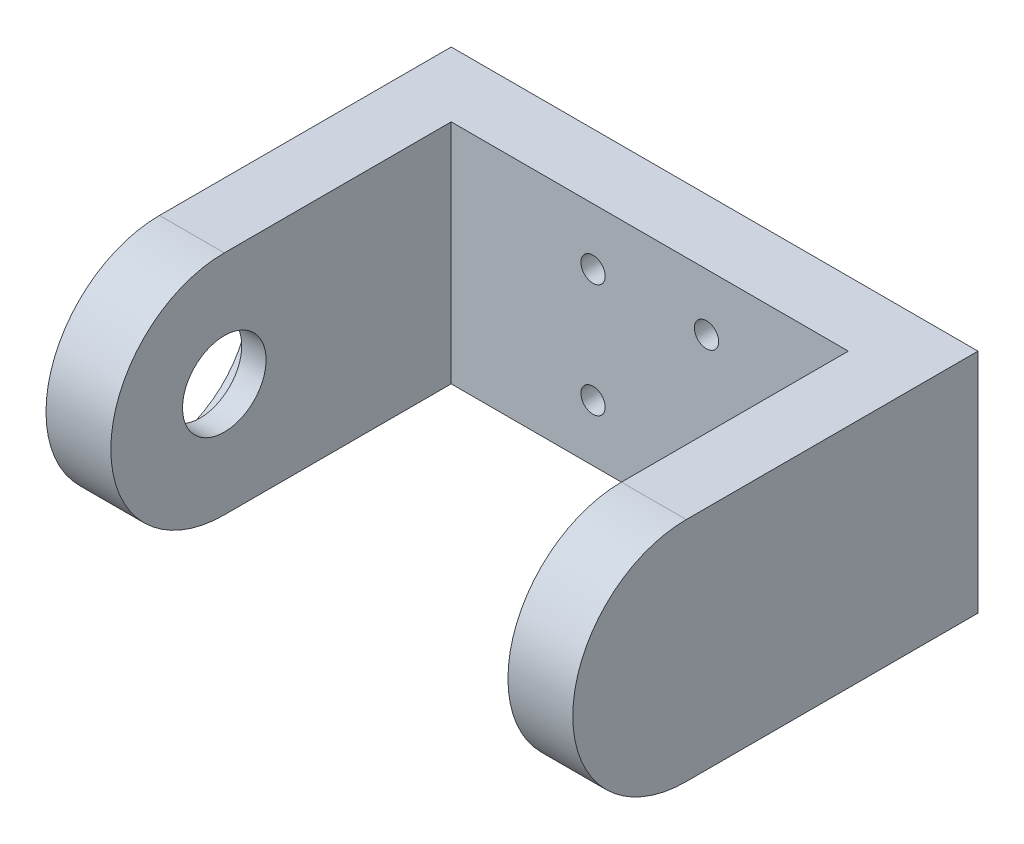
from build123d import *

# Parameters (mm, degrees)
CROQUIS1_W              = 65
CROQUIS1_H              = 28
SALIENTE_EXTRUIR1_DEPTH = 8
CROQUIS2_W              = 8
CROQUIS2_H              = 28
SALIENTE_EXTRUIR2_DEPTH = 28
CROQUIS3_R              = 14
SALIENTE_EXTRUIR3_DEPTH = 8
CROQUIS4_R              = 14
SALIENTE_EXTRUIR4_DEPTH = 8
CROQUIS5_R              = 11.115
CORTAR_EXTRUIR1_DEPTH   = 5
CROQUIS6_R              = 5.155
CORTAR_EXTRUIR2_DEPTH   = 8
CORTAR_EXTRUIR3_START   = -8
CROQUIS7_R              = 6.5
CORTAR_EXTRUIR3_DEPTH   = 5
CROQUIS8_R              = 1.5
CORTAR_EXTRUIR4_DEPTH   = 8


with BuildPart() as part:
    # Croquis1 → Saliente-Extruir1 (new body)
    with BuildSketch(Plane.XY):
        with Locations((32.5, 14)):
            Rectangle(CROQUIS1_W, CROQUIS1_H)
    extrude(amount=SALIENTE_EXTRUIR1_DEPTH)

    # Croquis2 → Saliente-Extruir2 (add)
    with BuildSketch(Plane.XY.offset(8)):
        with Locations((4, 14)):
            Rectangle(CROQUIS2_W, CROQUIS2_H)
        with Locations((61, 14)):
            Rectangle(CROQUIS2_W, CROQUIS2_H)
    extrude(amount=SALIENTE_EXTRUIR2_DEPTH)

    # Croquis3 → Saliente-Extruir3 (add)
    with BuildSketch(Plane.ZY):
        with Locations((36, 14)):
            Circle(CROQUIS3_R)
    extrude(amount=-SALIENTE_EXTRUIR3_DEPTH)

    # Croquis4 → Saliente-Extruir4 (add)
    with BuildSketch(Plane(origin=(65, 0, 0), x_dir=(0, 0, -1), z_dir=(1, 0, 0))):
        with Locations((-36, 14)):
            Circle(CROQUIS4_R)
    extrude(amount=-SALIENTE_EXTRUIR4_DEPTH)

    # Croquis5 → Cortar-Extruir1 (cut)
    with BuildSketch(Plane.ZY):
        with Locations((36, 14)):
            Circle(CROQUIS5_R)
    extrude(amount=-CORTAR_EXTRUIR1_DEPTH, mode=Mode.SUBTRACT)

    # Croquis6 → Cortar-Extruir2 (cut)
    with BuildSketch(Plane.ZY):
        with Locations((36, 14)):
            Circle(CROQUIS6_R)
    extrude(amount=-CORTAR_EXTRUIR2_DEPTH, mode=Mode.SUBTRACT)

    # Croquis7 → Cortar-Extruir3 (cut)
    with BuildSketch(Plane(origin=(65, 0, 0), x_dir=(0, 0, -1), z_dir=(1, 0, 0)).offset(CORTAR_EXTRUIR3_START)):
        with Locations((-36, 14)):
            Circle(CROQUIS7_R)
    extrude(amount=CORTAR_EXTRUIR3_DEPTH, mode=Mode.SUBTRACT)

    # Croquis8 → Cortar-Extruir4 (cut)
    with BuildSketch(Plane.XY.offset(8)):
        with Locations((39.5, 21)):
            Circle(CROQUIS8_R)
        with Locations((25.5, 21)):
            Circle(CROQUIS8_R)
        with Locations((25.5, 7)):
            Circle(CROQUIS8_R)
        with Locations((39.5, 7)):
            Circle(CROQUIS8_R)
    extrude(amount=-CORTAR_EXTRUIR4_DEPTH, mode=Mode.SUBTRACT)


solid = part.part
